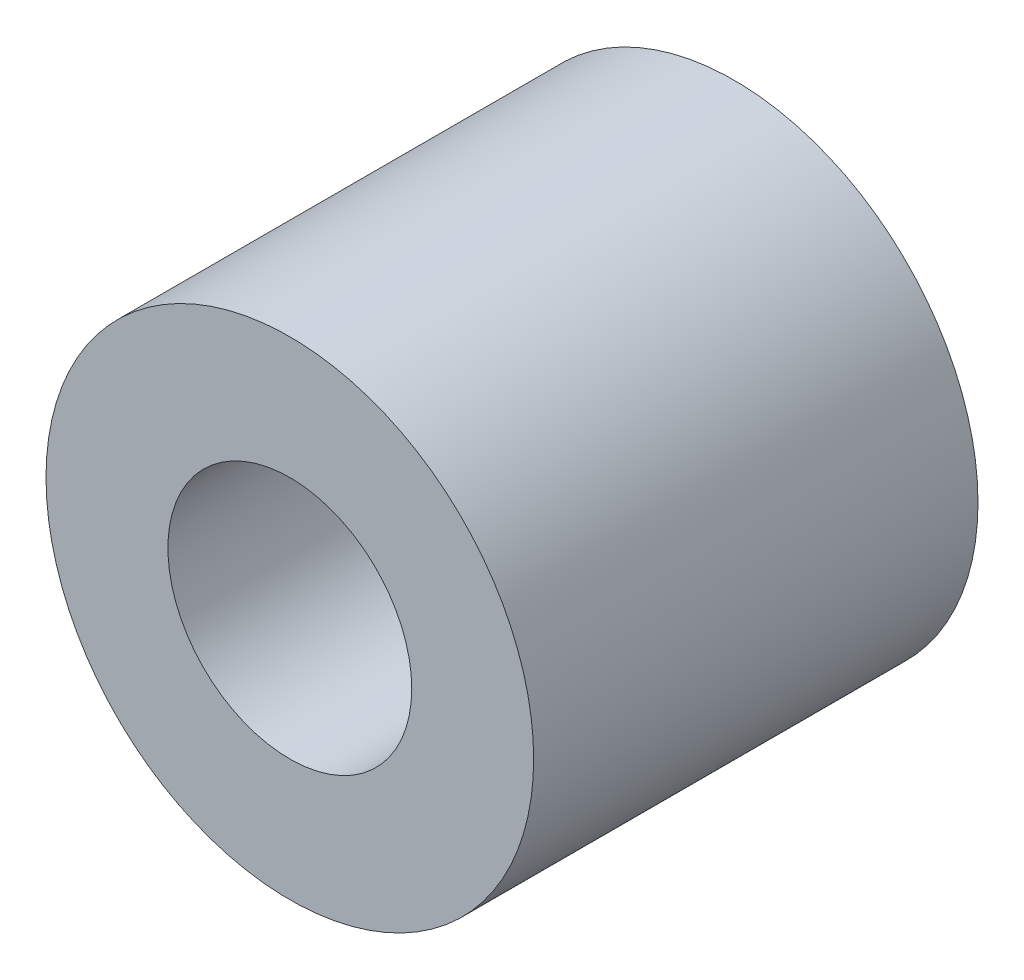
from build123d import *

# Parameters (mm, degrees)
SKETCH_1_R      = 4.5
SKETCH_1_R_2    = 2.25
EXTRUDE_1_DEPTH = 8.2


with BuildPart() as part:
    # 草图1 → 凸台-拉伸1 (new body)
    with BuildSketch(Plane.XY):
        Circle(SKETCH_1_R)
        Circle(SKETCH_1_R_2, mode=Mode.SUBTRACT)
    extrude(amount=EXTRUDE_1_DEPTH)


solid = part.part
